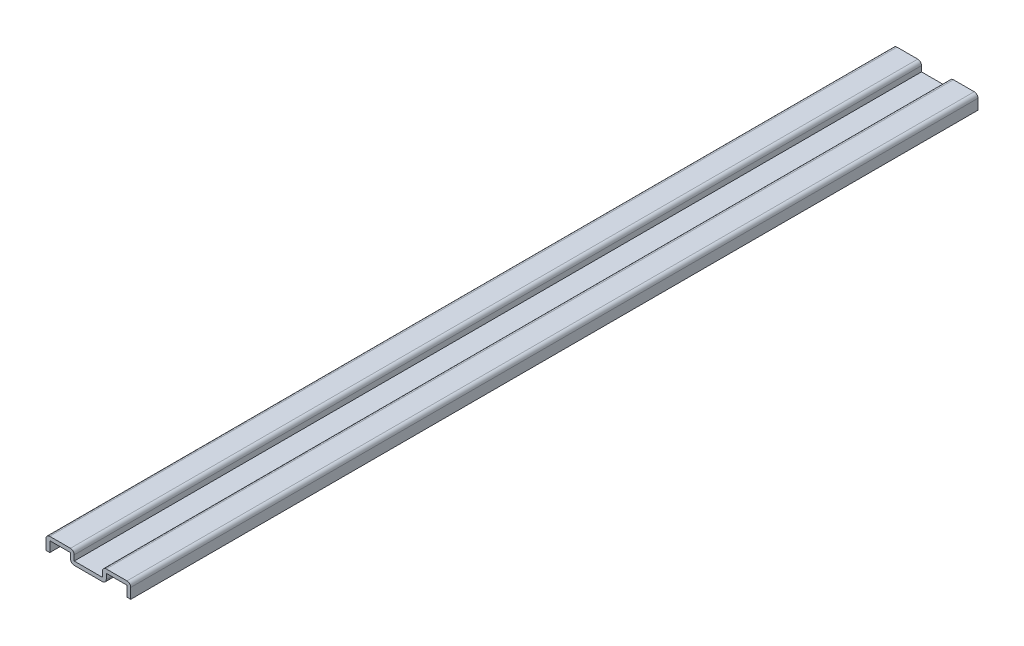
from build123d import *

# Parameters (mm, degrees)
EXTRUDE_THIN1_DEPTH = 285.75
FILLET1_R           = 1.27


with BuildPart() as part:
    # Sketch1 → Extrude-Thin1 (new body)
    with BuildSketch(Plane.XY):
        Polygon((-14.2875, 0), (-14.2875, 4.7625), (-4.7625, 4.7625), (-4.7625, 1.666875), (4.7625, 1.666875), (4.7625, 4.7625), (14.2875, 4.7625), (14.2875, 0), (13.0175, 0), (13.0175, 3.4925), (6.0325, 3.4925), (6.0325, 0.396875), (-6.0325, 0.396875), (-6.0325, 3.4925), (-13.0175, 3.4925), (-13.0175, 0), align=None)
    extrude(amount=-EXTRUDE_THIN1_DEPTH)

    # Fillet1
    fillet1_edges = [part.edges().sort_by_distance(p)[0] for p in [
        (-14.2875, 4.7625, -142.875),
        (-4.7625, 4.7625, -142.875),
        (4.7625, 4.7625, -142.875),
        (14.2875, 4.7625, -142.875),
        (6.0325, 0.396875, -142.875),
        (-6.0325, 0.396875, -142.875),
    ]]
    fillet(fillet1_edges, radius=FILLET1_R)


solid = part.part
